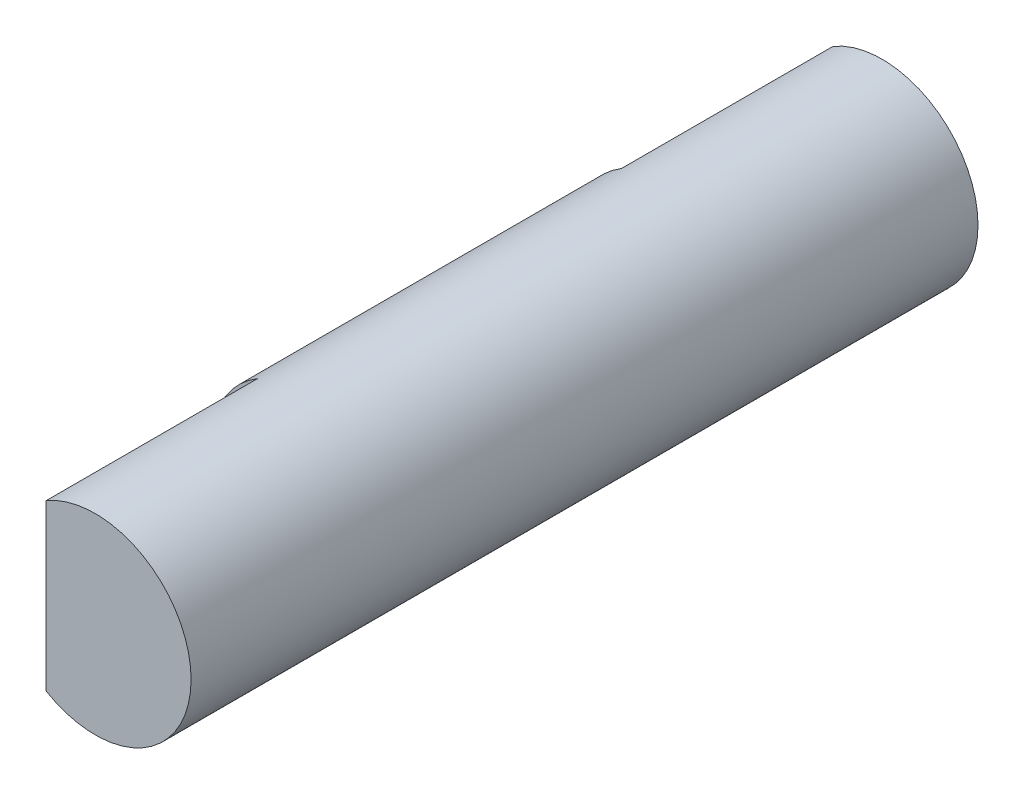
from build123d import *

# Parameters (mm, degrees)
SKETCH2_R           = 1.95
BOSS_EXTRUDE1_DEPTH = 8
CUT_EXTRUDE1_DEPTH  = 4.3


with BuildPart() as part:
    # Sketch2 → Boss-Extrude1 (new body, symmetric)
    with BuildSketch(Plane.XY):
        Circle(SKETCH2_R)
    extrude(amount=BOSS_EXTRUDE1_DEPTH, both=True)

    # Sketch4 → Cut-Extrude1 (cut)
    with BuildSketch(Plane(origin=(0, 0, -8), x_dir=(-1, 0, 0), z_dir=(0, 0, -1))):
        with BuildLine():
            Line((1, 1.674066904), (1, -1.674066904))
            ThreePointArc((1, -1.674066904), (1.95, 0), (1, 1.674066904))
        make_face()
    cut_extrude1 = extrude(amount=-CUT_EXTRUDE1_DEPTH, mode=Mode.SUBTRACT)

    # Mirror1: Cut-Extrude1 across plane
    add(cut_extrude1.mirror(Plane.XY), mode=Mode.SUBTRACT)


solid = part.part
